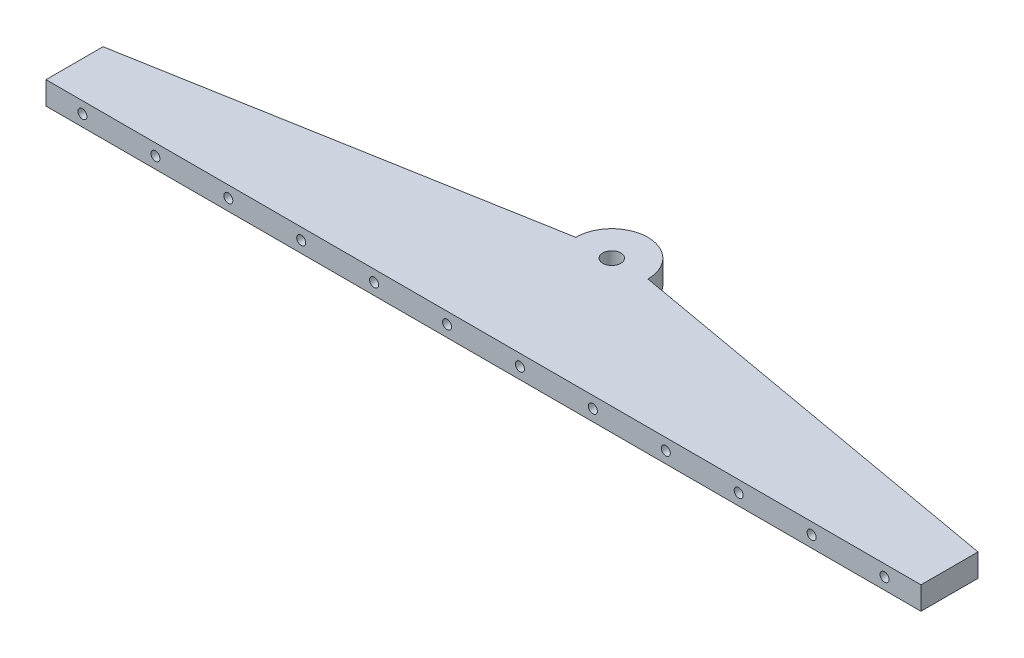
from build123d import *

# Parameters (mm, degrees)
SKETCH1_W                       = 242.4
SKETCH1_H                       = 71.1
BOSS_EXTRUDE1_DEPTH             = 6.35
SKETCH2_OUTSIDE_W               = 294.938
SKETCH2_OUTSIDE_H               = 123.638
CUT_EXTRUDE1_DEPTH              = 10
TAP_DRILL_FOR_M3X0_5_TAP1_D     = 2.5
TAP_DRILL_FOR_M3X0_5_TAP1_DEPTH = 6
TAP_DRILL_FOR_M3X0_5_TAP1_TIP   = 0.751075774
TAP_DRILL_FOR_M6X1_0_TAP1_D     = 5


with BuildPart() as part:
    # Sketch1 → Boss-Extrude1 (new body)
    with BuildSketch(Plane(origin=(0, 0, 0), x_dir=(1, 0, 0), z_dir=(0, 1, 0))):
        with Locations((121.2, 35.55)):
            Rectangle(SKETCH1_W, SKETCH1_H)
    extrude(amount=BOSS_EXTRUDE1_DEPTH)

    # Sketch2 outside → Cut-Extrude1 (cut)
    with BuildSketch(Plane(origin=(0, 6.35, 0), x_dir=(1, 0, 0), z_dir=(0, 1, 0))):
        with Locations((121.2, 35.55)):
            Rectangle(SKETCH2_OUTSIDE_W, SKETCH2_OUTSIDE_H)
        with BuildLine():
            Line((0, 0), (0, 15.796122239))
            Line((0, 15.796122239), (111.2, 35.55))
            ThreePointArc((111.2, 35.55), (121.2, 45.55), (131.2, 35.55))
            Line((131.2, 35.55), (242.4, 15.796122239))
            Line((242.4, 15.796122239), (242.4, 0))
            Line((242.4, 0), (0, 0))
        make_face(mode=Mode.SUBTRACT)
    extrude(amount=-CUT_EXTRUDE1_DEPTH, mode=Mode.SUBTRACT)

    # Tap Drill for M3x0.5 Tap1
    with Locations(Plane.XY):
        with Locations((232.3, 3.175), (10.1, 3.175), (30.3, 3.175), (50.5, 3.175), (70.7, 3.175), (90.9, 3.175), (111.1, 3.175), (131.3, 3.175), (151.5, 3.175), (171.7, 3.175), (191.9, 3.175), (212.1, 3.175)):
            Hole(TAP_DRILL_FOR_M3X0_5_TAP1_D / 2, depth=TAP_DRILL_FOR_M3X0_5_TAP1_DEPTH)
            with Locations((0, 0, -(TAP_DRILL_FOR_M3X0_5_TAP1_DEPTH + TAP_DRILL_FOR_M3X0_5_TAP1_TIP / 2))):  # 118° drill point
                Cone(0, TAP_DRILL_FOR_M3X0_5_TAP1_D / 2, TAP_DRILL_FOR_M3X0_5_TAP1_TIP, mode=Mode.SUBTRACT)

    # Tap Drill for M6x1.0 Tap1 (through all)
    with Locations(Plane(origin=(0, 6.35, 0), x_dir=(1, 0, 0), z_dir=(0, 1, 0))):
        with Locations((121.2, 35.55)):
            Hole(TAP_DRILL_FOR_M6X1_0_TAP1_D / 2)


solid = part.part
